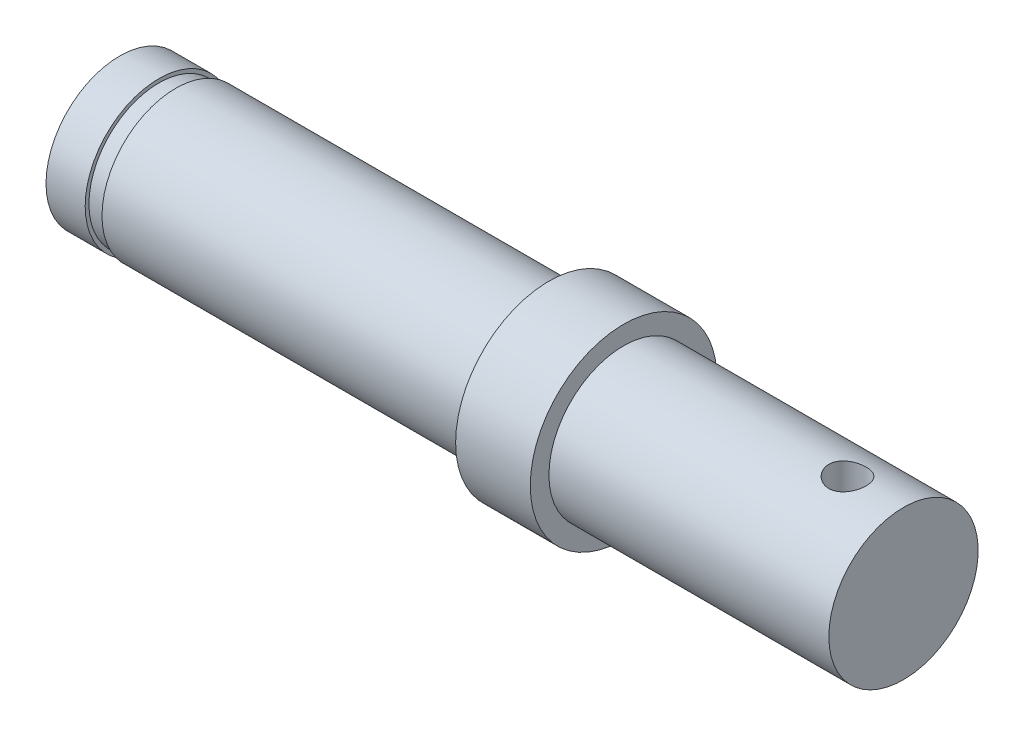
from build123d import *

# Parameters (mm, degrees)
SKETCH_2_R          = 1
CUT_EXTRUDE_1_DEPTH = 5


with BuildPart() as part:
    # 草图1 → 旋转1 (revolve)
    with BuildSketch(Plane.XY):
        Polygon((-15.499429975, 0), (26.500570025, 0), (26.500570025, 4), (11.500570025, 4), (11.500570025, 5), (7.500570025, 5), (7.500570025, 3.95), (-12.499429975, 3.95), (-12.499429975, 3.75), (-13.399429975, 3.75), (-13.399429975, 3.95), (-15.499429975, 3.95), align=None)
    revolve(axis=Axis((-15.499429975, 0, 0), (1, 0, 0)))

    # 草图2 → 切除-拉伸1 (cut, symmetric)
    with BuildSketch(Plane(origin=(0, 0, 0), x_dir=(1, 0, 0), z_dir=(0, 1, 0))):
        with Locations((23.500570025, 0)):
            Circle(SKETCH_2_R)
    extrude(amount=CUT_EXTRUDE_1_DEPTH, both=True, mode=Mode.SUBTRACT)


solid = part.part
